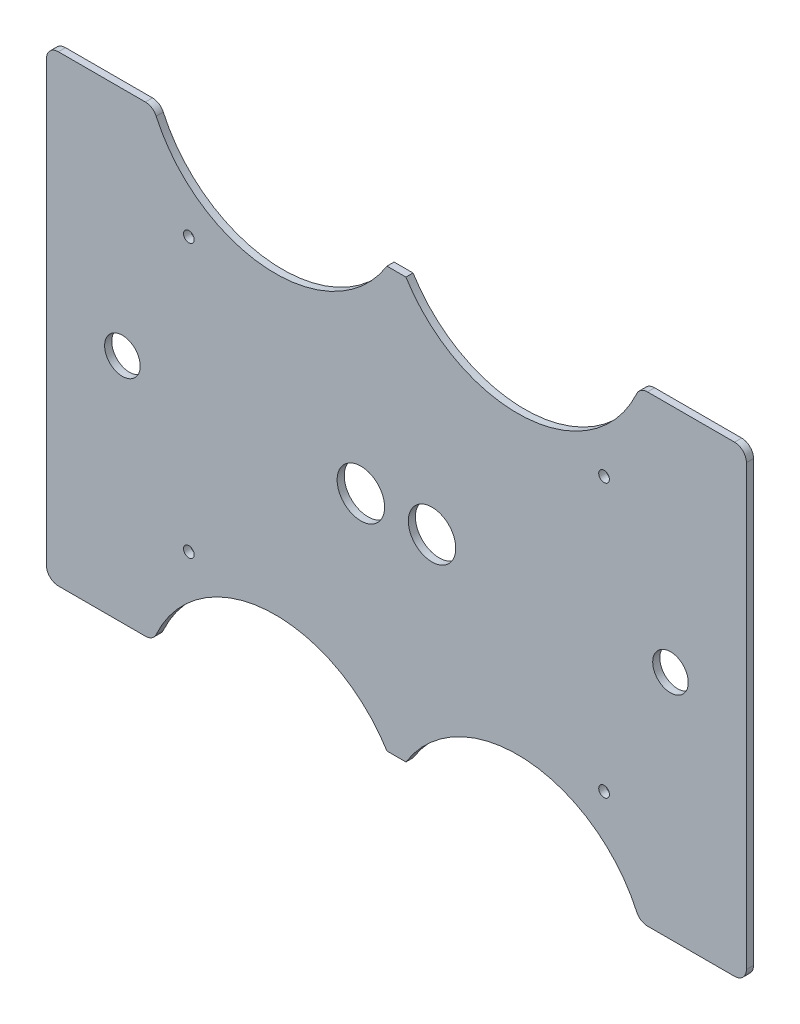
from build123d import *

# Parameters (mm, degrees)
ESQUISSE1_R        = 2.25
ESQUISSE1_R_2      = 7.5
ESQUISSE1_R_3      = 10
BOSS_EXTRU_1_DEPTH = 3


with BuildPart() as part:
    # Esquisse1 → Boss.-Extru.1 (new body)
    with BuildSketch(Plane.XY):
        with BuildLine():
            Line((5, 0), (41.684938398, 0))
            ThreePointArc((41.684938398, 0), (44.389031178, -0.794303597), (46.23397571, -2.924847105))
            ThreePointArc((46.23397571, -2.924847105), (93.045262331, -35.129096737), (143.5, -9))
            Line((143.5, -9), (151.5, -9))
            ThreePointArc((151.5, -9), (201.954737669, -35.129096737), (248.76602429, -2.924847105))
            ThreePointArc((248.76602429, -2.924847105), (250.610968822, -0.794303597), (253.315061602, 0))
            Line((253.315061602, 0), (290, 0))
            ThreePointArc((290, 0), (293.535533906, -1.464466094), (295, -5))
            Line((295, -5), (295, -190))
            ThreePointArc((295, -190), (293.535533906, -193.535533906), (290, -195))
            Line((290, -195), (253.315061602, -195))
            ThreePointArc((253.315061602, -195), (250.610968822, -194.205696403), (248.76602429, -192.075152895))
            ThreePointArc((248.76602429, -192.075152895), (201.954737669, -159.870903263), (151.5, -186))
            Line((151.5, -186), (143.5, -186))
            ThreePointArc((143.5, -186), (93.045262331, -159.870903263), (46.23397571, -192.075152895))
            ThreePointArc((46.23397571, -192.075152895), (44.389031178, -194.205696403), (41.684938398, -195))
            Line((41.684938398, -195), (5, -195))
            ThreePointArc((5, -195), (1.464466094, -193.535533906), (0, -190))
            Line((0, -190), (0, -5))
            ThreePointArc((0, -5), (1.464466094, -1.464466094), (5, 0))
        make_face()
        with Locations((60, -40)):
            Circle(ESQUISSE1_R, mode=Mode.SUBTRACT)
        with Locations((32, -97.5)):
            Circle(ESQUISSE1_R_2, mode=Mode.SUBTRACT)
        with Locations((263, -97.5)):
            Circle(ESQUISSE1_R_2, mode=Mode.SUBTRACT)
        with Locations((132.5, -97.5)):
            Circle(ESQUISSE1_R_3, mode=Mode.SUBTRACT)
        with Locations((162.5, -97.5)):
            Circle(ESQUISSE1_R_3, mode=Mode.SUBTRACT)
        with Locations((235, -40)):
            Circle(ESQUISSE1_R, mode=Mode.SUBTRACT)
        with Locations((235, -155)):
            Circle(ESQUISSE1_R, mode=Mode.SUBTRACT)
        with Locations((60, -155)):
            Circle(ESQUISSE1_R, mode=Mode.SUBTRACT)
    extrude(amount=BOSS_EXTRU_1_DEPTH)


solid = part.part
